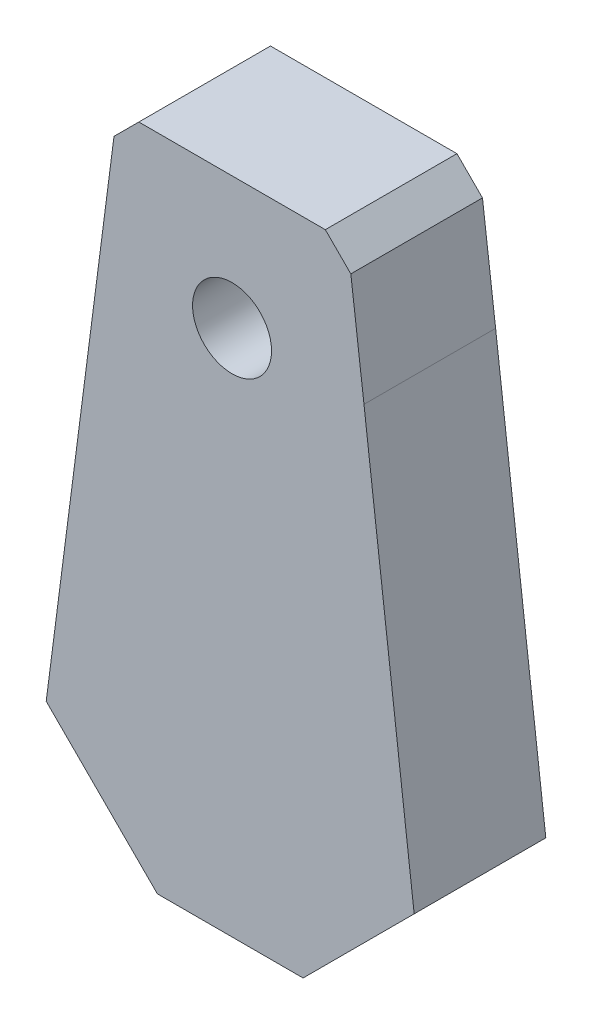
from build123d import *

# Parameters (mm, degrees)
MODEL_R                  = 1.8
RESSALTO_EXTRUS_O1_DEPTH = 6


with BuildPart() as part:
    # Model → Ressalto-extrusão1 (new body)
    with BuildSketch(Plane.XY):
        Polygon((36.676362522, 11.559126959), (43.318311298, 11.559126959), (48.38117681, 16.621992471), (46.093165841, 35.592208395), (45.494331575, 40.442304919), (44.330954819, 41.605681674), (35.830954819, 41.605681674), (34.69889139, 40.473618245), (31.60820441, 16.627285071), align=None)
        with Locations((40.079692562, 35.592208395)):
            Circle(MODEL_R, mode=Mode.SUBTRACT)
    extrude(amount=RESSALTO_EXTRUS_O1_DEPTH)


solid = part.part
